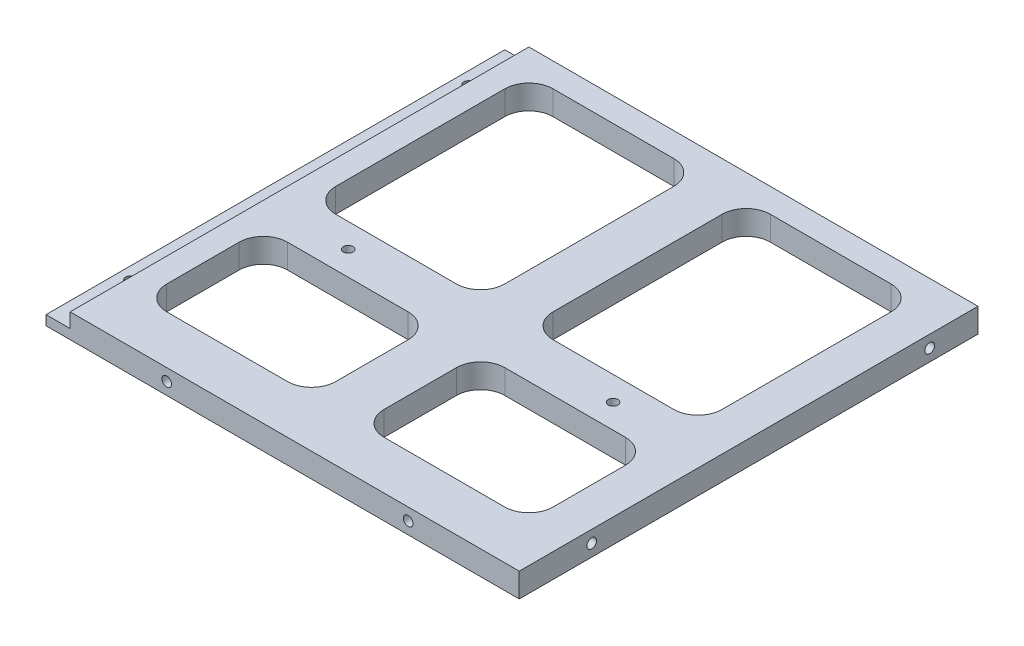
from build123d import *

# Parameters (mm, degrees)
SKETCH1_W                             = 98
SKETCH1_H                             = 95
BOSS_EXTRUDE1_DEPTH                   = 5
SKETCH6_W                             = 5
SKETCH6_H                             = 95
CUT_EXTRUDE1_DEPTH                    = 3
CUT_EXTRUDE2_DEPTH                    = 6
TAP_DRILL_FOR_M2X0_4_TAP4_D           = 2
TAP_DRILL_FOR_M2X0_4_TAP1_D           = 2
TAP_DRILL_FOR_M2X0_4_TAP1_CSINK_D     = 4.2
TAP_DRILL_FOR_M2X0_4_TAP1_CSINK_ANGLE = 90
TAP_DRILL_FOR_M2X0_4_TAP3_D           = 2
TAP_DRILL_FOR_M2X0_4_TAP3_DEPTH       = 6
TAP_DRILL_FOR_M2X0_4_TAP3_TIP         = 0.600860619
TAP_DRILL_FOR_M2X0_4_TAP5_D           = 2
TAP_DRILL_FOR_M2X0_4_TAP5_DEPTH       = 4
TAP_DRILL_FOR_M2X0_4_TAP5_TIP         = 0.600860619
TAP_DRILL_FOR_M2X0_4_TAP6_D           = 2
TAP_DRILL_FOR_M2X0_4_TAP6_DEPTH       = 7
TAP_DRILL_FOR_M2X0_4_TAP6_TIP         = 0.600860619


with BuildPart() as part:
    # Sketch1 → Boss-Extrude1 (new body)
    with BuildSketch(Plane(origin=(0, 0, 0), x_dir=(1, 0, 0), z_dir=(0, 1, 0))):
        with Locations((49, 47.5)):
            Rectangle(SKETCH1_W, SKETCH1_H)
    extrude(amount=BOSS_EXTRUDE1_DEPTH)

    # Sketch6 → Cut-Extrude1 (cut)
    with BuildSketch(Plane(origin=(0, 5, 0), x_dir=(1, 0, 0), z_dir=(0, 1, 0))):
        with Locations((2.5, 47.5)):
            Rectangle(SKETCH6_W, SKETCH6_H)
    extrude(amount=-CUT_EXTRUDE1_DEPTH, mode=Mode.SUBTRACT)

    # Sketch5 → Cut-Extrude2 (cut, through all)
    with BuildSketch(Plane(origin=(0, 5, 0), x_dir=(1, 0, 0), z_dir=(0, 1, 0))):
        with BuildLine():
            Line((15, 90), (40, 90))
            ThreePointArc((40, 90), (43.535533906, 88.535533906), (45, 85))
            Line((45, 85), (45, 50))
            ThreePointArc((45, 50), (43.535533906, 46.464466094), (40, 45))
            Line((40, 45), (15, 45))
            ThreePointArc((15, 45), (11.464466094, 46.464466094), (10, 50))
            Line((10, 50), (10, 85))
            ThreePointArc((10, 85), (11.464466094, 88.535533906), (15, 90))
        make_face()
        with BuildLine():
            Line((60, 90), (85, 90))
            ThreePointArc((85, 90), (88.535533906, 88.535533906), (90, 85))
            Line((90, 85), (90, 50))
            ThreePointArc((90, 50), (88.535533906, 46.464466094), (85, 45))
            Line((85, 45), (60, 45))
            ThreePointArc((60, 45), (56.464466094, 46.464466094), (55, 50))
            Line((55, 50), (55, 85))
            ThreePointArc((55, 85), (56.464466094, 88.535533906), (60, 90))
        make_face()
        with BuildLine():
            Line((60, 35), (85, 35))
            ThreePointArc((85, 35), (88.535533906, 33.535533906), (90, 30))
            Line((90, 30), (90, 15))
            ThreePointArc((90, 15), (88.535533906, 11.464466094), (85, 10))
            Line((85, 10), (60, 10))
            ThreePointArc((60, 10), (56.464466094, 11.464466094), (55, 15))
            Line((55, 15), (55, 30))
            ThreePointArc((55, 30), (56.464466094, 33.535533906), (60, 35))
        make_face()
        with BuildLine():
            Line((15, 35), (40, 35))
            ThreePointArc((40, 35), (43.535533906, 33.535533906), (45, 30))
            Line((45, 30), (45, 15))
            ThreePointArc((45, 15), (43.535533906, 11.464466094), (40, 10))
            Line((40, 10), (15, 10))
            ThreePointArc((15, 10), (11.464466094, 11.464466094), (10, 15))
            Line((10, 15), (10, 30))
            ThreePointArc((10, 30), (11.464466094, 33.535533906), (15, 35))
        make_face()
    extrude(amount=-CUT_EXTRUDE2_DEPTH, mode=Mode.SUBTRACT)

    # Tap Drill for M2x0.4 Tap4 (through all)
    with Locations(Plane(origin=(22.568, 5, -40), x_dir=(0, 0, 1), z_dir=(0, 1, 0))):
        with Locations((0, 0), (0, 54.864)):
            Hole(TAP_DRILL_FOR_M2X0_4_TAP4_D / 2)

    # Tap Drill for M2x0.4 Tap1 (through all)
    with Locations(Plane(origin=(2.5, 0, -15), x_dir=(0, 0, -1), z_dir=(0, -1, 0))):
        with Locations((0, 0), (70, 0)):
            CounterSinkHole(TAP_DRILL_FOR_M2X0_4_TAP1_D / 2, TAP_DRILL_FOR_M2X0_4_TAP1_CSINK_D / 2, counter_sink_angle=TAP_DRILL_FOR_M2X0_4_TAP1_CSINK_ANGLE)

    # Tap Drill for M2x0.4 Tap3
    with Locations(Plane(origin=(98, 2.5, -15), x_dir=(0, 0, 1), z_dir=(1, 0, 0))):
        with Locations((0, 0), (-70, 0)):
            Hole(TAP_DRILL_FOR_M2X0_4_TAP3_D / 2, depth=TAP_DRILL_FOR_M2X0_4_TAP3_DEPTH)
            with Locations((0, 0, -(TAP_DRILL_FOR_M2X0_4_TAP3_DEPTH + TAP_DRILL_FOR_M2X0_4_TAP3_TIP / 2))):  # 118° drill point
                Cone(0, TAP_DRILL_FOR_M2X0_4_TAP3_D / 2, TAP_DRILL_FOR_M2X0_4_TAP3_TIP, mode=Mode.SUBTRACT)

    # Tap Drill for M2x0.4 Tap5
    with Locations(Plane(origin=(92.75, 2.5, -95), x_dir=(-1, 0, 0), z_dir=(0, 0, -1))):
        with Locations((0, 0), (85.5, 0)):
            Hole(TAP_DRILL_FOR_M2X0_4_TAP5_D / 2, depth=TAP_DRILL_FOR_M2X0_4_TAP5_DEPTH)
            with Locations((0, 0, -(TAP_DRILL_FOR_M2X0_4_TAP5_DEPTH + TAP_DRILL_FOR_M2X0_4_TAP5_TIP / 2))):  # 118° drill point
                Cone(0, TAP_DRILL_FOR_M2X0_4_TAP5_D / 2, TAP_DRILL_FOR_M2X0_4_TAP5_TIP, mode=Mode.SUBTRACT)

    # Tap Drill for M2x0.4 Tap6
    with Locations(Plane(origin=(25, 2.5, 0), x_dir=(1, 0, 0), z_dir=(0, 0, 1))):
        with Locations((0, 0), (50, 0)):
            Hole(TAP_DRILL_FOR_M2X0_4_TAP6_D / 2, depth=TAP_DRILL_FOR_M2X0_4_TAP6_DEPTH)
            with Locations((0, 0, -(TAP_DRILL_FOR_M2X0_4_TAP6_DEPTH + TAP_DRILL_FOR_M2X0_4_TAP6_TIP / 2))):  # 118° drill point
                Cone(0, TAP_DRILL_FOR_M2X0_4_TAP6_D / 2, TAP_DRILL_FOR_M2X0_4_TAP6_TIP, mode=Mode.SUBTRACT)


solid = part.part
